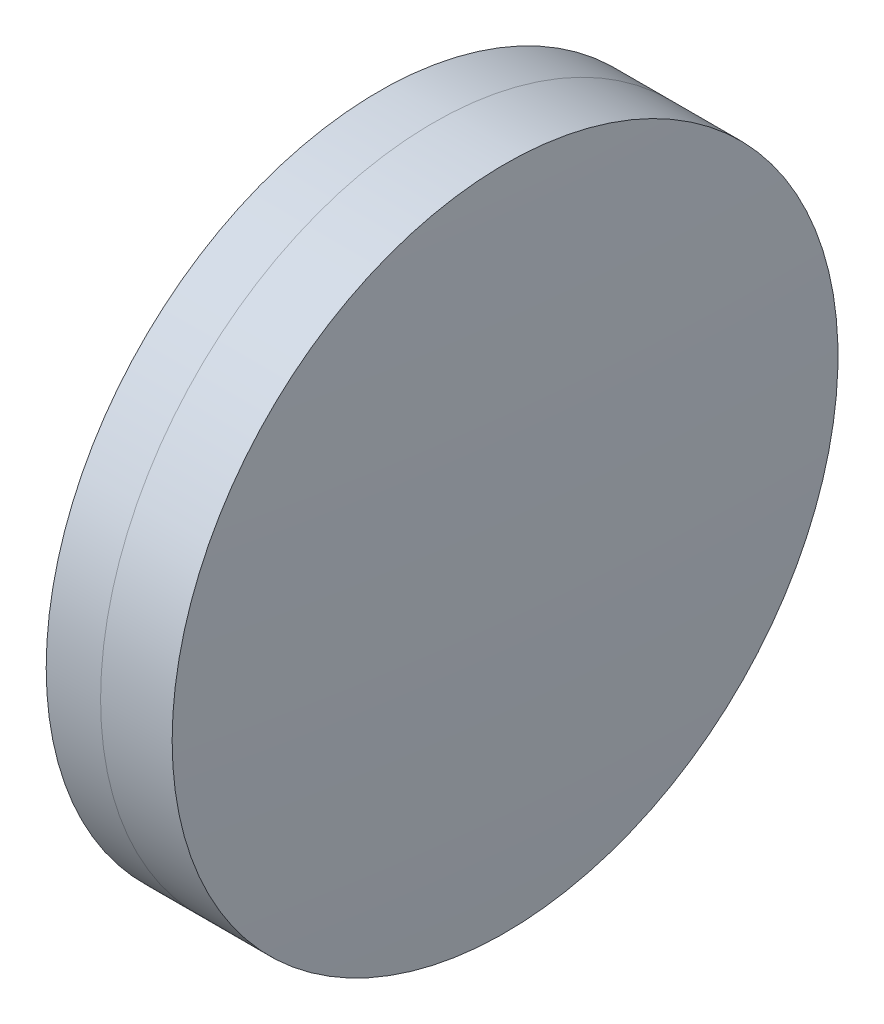
from build123d import *


with BuildPart() as part:
    # 草图1 one side → 旋转1 (revolve)
    with BuildSketch(Plane(origin=(0, 0, 0), x_dir=(1, 0, 0), z_dir=(0, 1, 0)), mode=Mode.PRIVATE) as revolve_1_sk:
        with BuildLine():
            ThreePointArc((91.870233394, 12.5), (91.401157877, 6.257821723), (91.244668974, 0))
            Line((91.244668974, 0), (94.894668974, 0))
            ThreePointArc((94.894668974, 0), (94.648688289, 6.269272887), (93.912258612, 12.5))
            Line((93.912258612, 12.5), (91.870233394, 12.5))
        make_face()
    revolve(revolve_1_sk.sketch.rotate(Axis((-9.702612178, 0, 0), (1, 0, 0)), 180), axis=Axis((-9.702612178, 0, 0), (1, 0, 0)))  # turned: the seam where the file's is


with BuildPart() as body_2:
    # 草图2 one side → 旋转3 (revolve)
    with BuildSketch(Plane(origin=(0, 0, 0), x_dir=(1, 0, 0), z_dir=(0, 1, 0)), mode=Mode.PRIVATE) as revolve_3_sk:
        with BuildLine():
            Line((96.599325406, 12.5), (93.912258612, 12.5))
            ThreePointArc((93.912258612, 12.5), (94.648688289, 6.269272887), (94.894668974, 0))
            Line((94.894668974, 0), (96.904668974, 0))
            ThreePointArc((96.904668974, 0), (96.828321698, 6.251864416), (96.599325406, 12.5))
        make_face()
    revolve(revolve_3_sk.sketch.rotate(Axis((-0.551919993, 0, 0), (1, 0, 0)), 180), axis=Axis((-0.551919993, 0, 0), (1, 0, 0)))  # turned: the seam where the file's is


solid = Compound([part.part, body_2.part])
